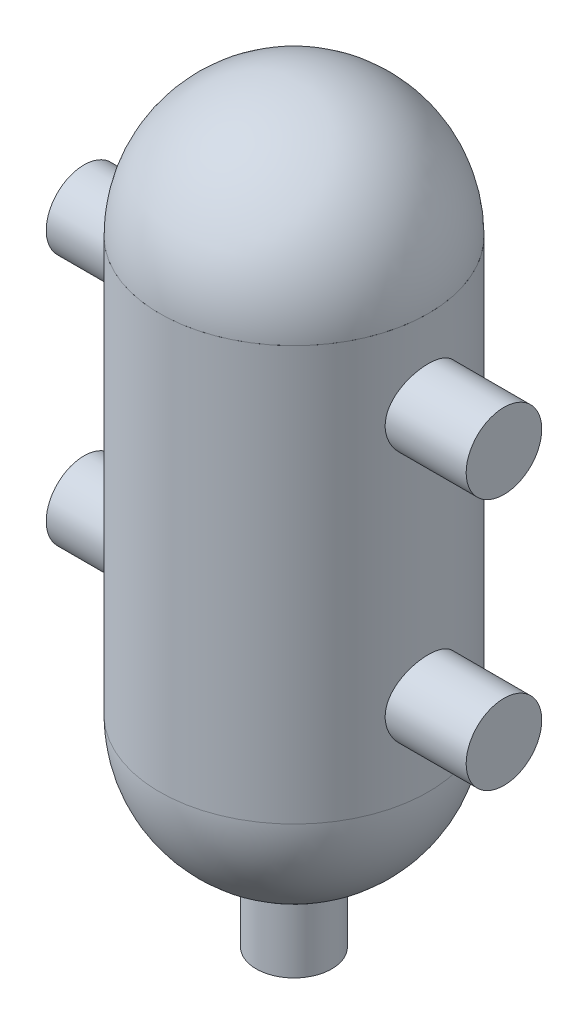
from build123d import *

# Parameters (mm, degrees)
SKETCH1_W           = 10
SKETCH1_H           = 113.33
SKETCH2_R           = 22.5
BOSS_EXTRUDE1_DEPTH = 125
SKETCH3_R           = 22.5
BOSS_EXTRUDE2_DEPTH = 120


with BuildPart() as part:
    # Sketch1 → Revolve1 (revolve)
    with BuildSketch(Plane.XY):
        Polygon((80, 113.33), (80, 123.33), (70, 123.33), (0, 123.33), (0, 113.33), (70, 113.33), align=None)
        with Locations((75, 56.665)):
            Rectangle(SKETCH1_W, SKETCH1_H)
        with BuildLine():
            Line((80, -123.33), (80, 0))
            Line((80, 0), (70, 0))
            Line((70, 0), (70, -123.33))
            ThreePointArc((70, -123.33), (49.497474683, -172.827474683), (0, -193.33))
            Line((0, -193.33), (0, -203.33))
            ThreePointArc((0, -203.33), (56.568542495, -179.898542495), (80, -123.33))
        make_face()
    revolve(axis=Axis((0, 203.33, 0), (0, -1, 0)))

    # Sketch2 → Boss-Extrude1 (add, symmetric)
    with BuildSketch(Plane(origin=(0, 0, 0), x_dir=(0, 0, -1), z_dir=(1, 0, 0))):
        with Locations((0, 75)):
            Circle(SKETCH2_R)
        with Locations((0, -75)):
            Circle(SKETCH2_R)
    extrude(amount=BOSS_EXTRUDE1_DEPTH, both=True)

    # Sketch3 → Boss-Extrude2 (add)
    with BuildSketch(Plane(origin=(0, -123.33, 0), x_dir=(1, 0, 0), z_dir=(0, 1, 0))):
        Circle(SKETCH3_R)
    extrude(amount=-BOSS_EXTRUDE2_DEPTH)


with BuildPart() as body_2:
    # Sketch1_3 → Revolve2 (revolve)
    with BuildSketch(Plane.XY):
        with BuildLine():
            Line((0, 203.33), (0, 193.33))
            ThreePointArc((0, 193.33), (49.497474683, 172.827474683), (70, 123.33))
            Line((70, 123.33), (80, 123.33))
            ThreePointArc((80, 123.33), (56.568542495, 179.898542495), (0, 203.33))
        make_face()
    revolve(axis=Axis((0, 203.33, 0), (0, -1, 0)))


solid = Compound([part.part, body_2.part])
